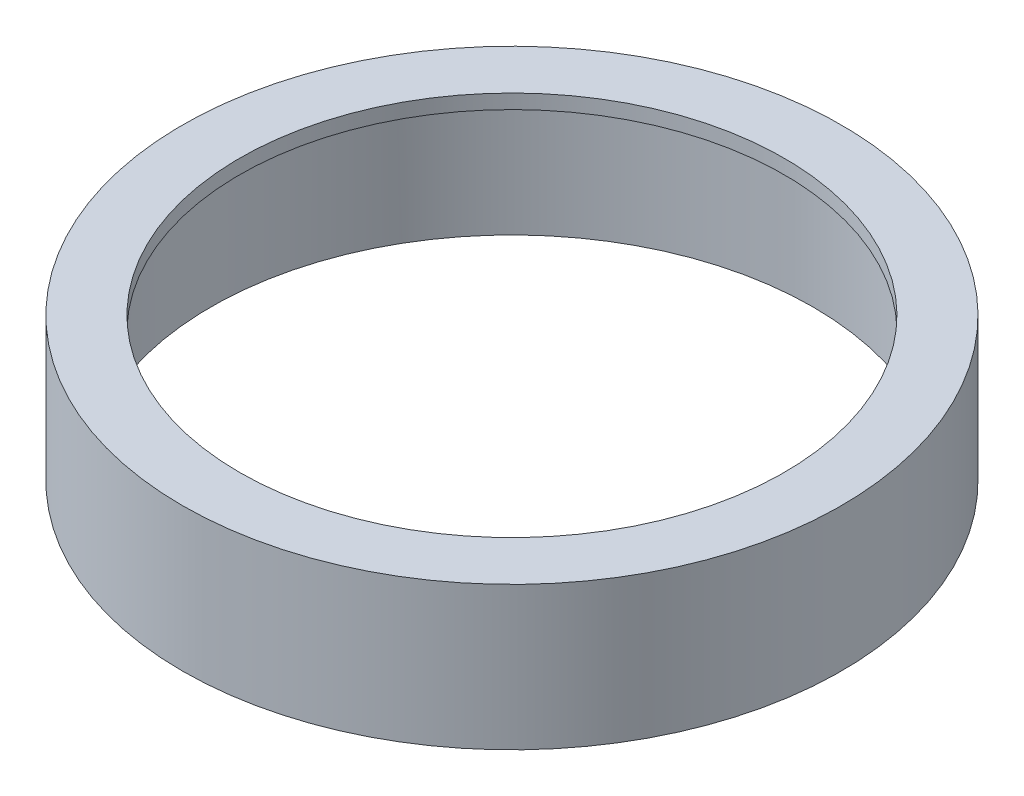
from build123d import *

# Parameters (mm, degrees)
SKETCH1_R           = 115
SKETCH1_R_2         = 105.05
BOSS_EXTRUDE1_DEPTH = 50
SKETCH2_R           = 105.05
SKETCH2_R_2         = 95
BOSS_EXTRUDE2_DEPTH = 5
SKETCH3_R           = 105.05
SKETCH3_R_2         = 101.75
CUT_EXTRUDE1_DEPTH  = 3


with BuildPart() as part:
    # Sketch1 → Boss-Extrude1 (new body)
    with BuildSketch(Plane(origin=(0, 0, 0), x_dir=(1, 0, 0), z_dir=(0, 1, 0))):
        Circle(SKETCH1_R)
        Circle(SKETCH1_R_2, mode=Mode.SUBTRACT)
    extrude(amount=BOSS_EXTRUDE1_DEPTH)

    # Sketch2 → Boss-Extrude2 (add)
    with BuildSketch(Plane(origin=(0, 50, 0), x_dir=(1, 0, 0), z_dir=(0, 1, 0))):
        Circle(SKETCH2_R)
        Circle(SKETCH2_R_2, mode=Mode.SUBTRACT)
    extrude(amount=-BOSS_EXTRUDE2_DEPTH)

    # Sketch3 → Cut-Extrude1 (cut)
    with BuildSketch(Plane.XZ.offset(-45)):
        Circle(SKETCH3_R)
        Circle(SKETCH3_R_2, mode=Mode.SUBTRACT)
    extrude(amount=-CUT_EXTRUDE1_DEPTH, mode=Mode.SUBTRACT)

    # Sketch6 → Cut-Revolve1 (revolve, cut)
    with BuildSketch(Plane.XY):
        Polygon((102, 48), (97, 45), (102, 45), align=None)
    revolve(axis=Axis((0, 48, 0), (0, -1, 0)), mode=Mode.SUBTRACT)


solid = part.part
